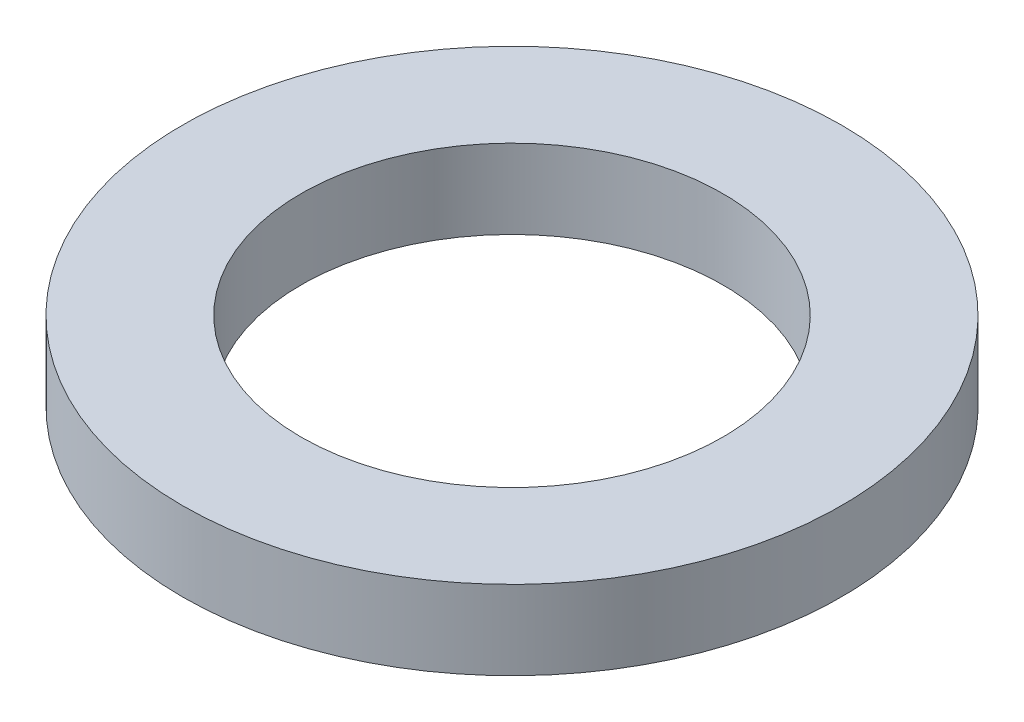
from build123d import *

# Parameters (mm, degrees)
SKETCH1_R           = 2.5
SKETCH1_R_2         = 1.6
BOSS_EXTRUDE1_DEPTH = 0.6


with BuildPart() as part:
    # Sketch1 → Boss-Extrude1 (new body)
    with BuildSketch(Plane(origin=(0, 0, 0), x_dir=(1, 0, 0), z_dir=(0, 1, 0))):
        Circle(SKETCH1_R)
        Circle(SKETCH1_R_2, mode=Mode.SUBTRACT)
    extrude(amount=BOSS_EXTRUDE1_DEPTH)


solid = part.part
